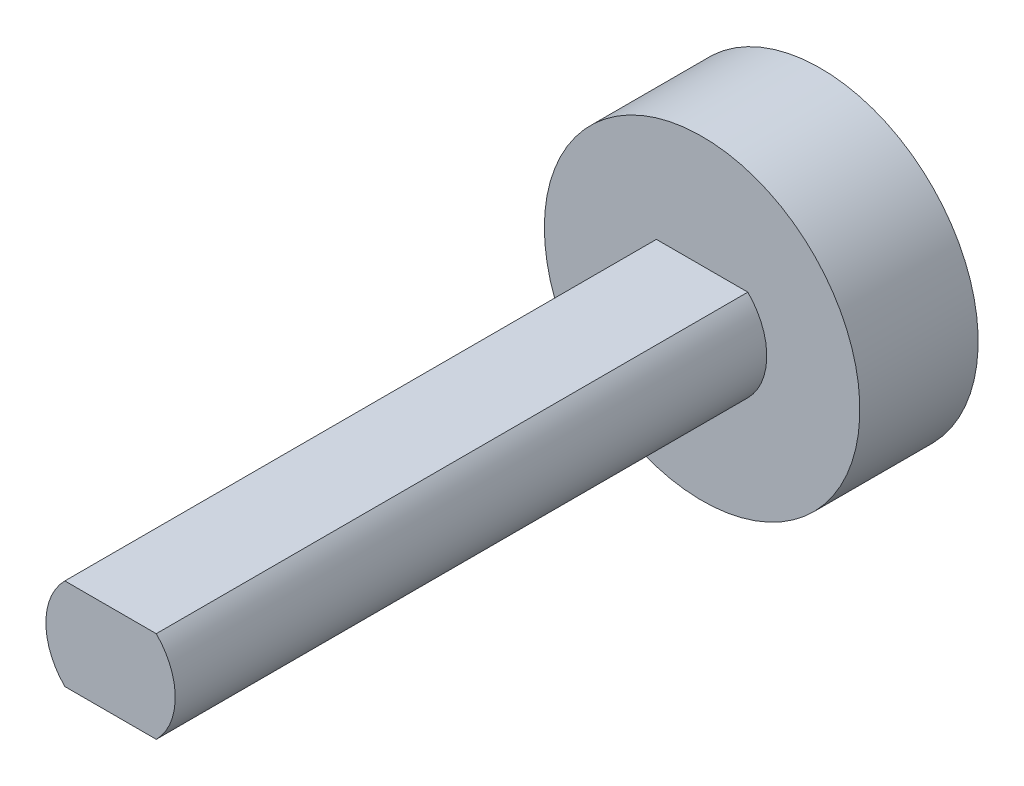
from build123d import *

# Parameters (mm, degrees)
BOSS_EXTRUDE1_DEPTH = 114.3
SKETCH3_R           = 25.401969389
BOSS_EXTRUDE2_DEPTH = 19.05


with BuildPart() as part:
    # Sketch1 → Boss-Extrude1 (new body)
    with BuildSketch(Plane.XY):
        with BuildLine():
            Line((-7.359452383, -7.368165079), (7.359452383, -7.368165079))
            ThreePointArc((7.359452383, -7.368165079), (10.414, 0), (7.359452383, 7.368165079))
            Line((7.359452383, 7.368165079), (-7.359452383, 7.368165079))
            ThreePointArc((-7.359452383, 7.368165079), (-10.414, 0), (-7.359452383, -7.368165079))
        make_face()
    extrude(amount=BOSS_EXTRUDE1_DEPTH)

    # Sketch3 → Boss-Extrude2 (add)
    with BuildSketch(Plane(origin=(0, 0, 0), x_dir=(-1, 0, 0), z_dir=(0, 0, -1))):
        Circle(SKETCH3_R)
    extrude(amount=-BOSS_EXTRUDE2_DEPTH)


solid = part.part
